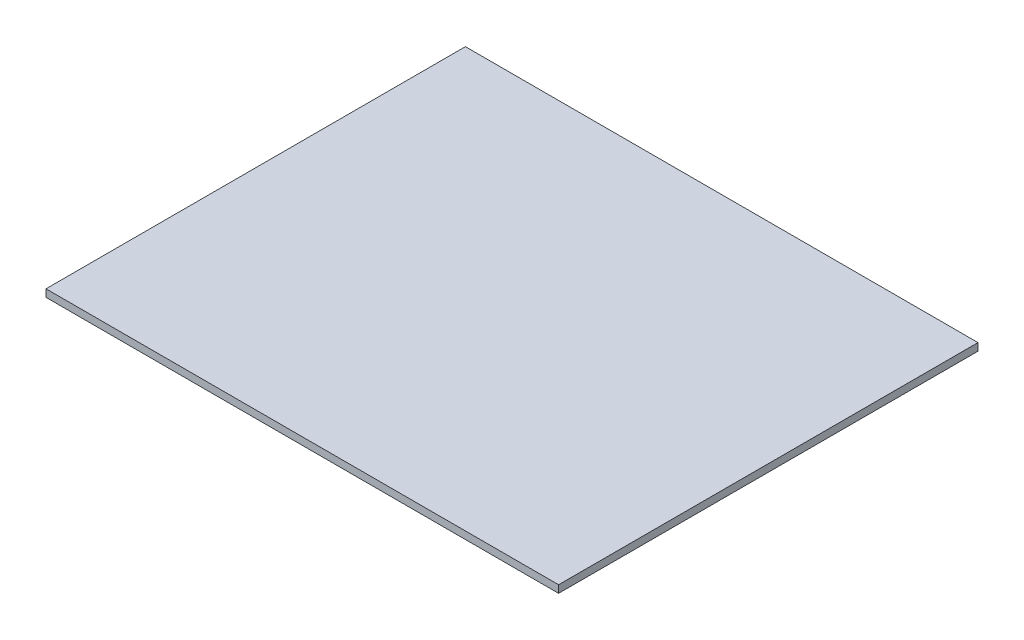
from build123d import *

# Parameters (mm, degrees)
SKETCH1_W           = 110
SKETCH1_H           = 90
BOSS_EXTRUDE1_DEPTH = 1.6


with BuildPart() as part:
    # Sketch1 → Boss-Extrude1 (new body)
    with BuildSketch(Plane(origin=(0, 0, 0), x_dir=(1, 0, 0), z_dir=(0, 1, 0))):
        with Locations((55, 45)):
            Rectangle(SKETCH1_W, SKETCH1_H)
    extrude(amount=BOSS_EXTRUDE1_DEPTH)


solid = part.part
